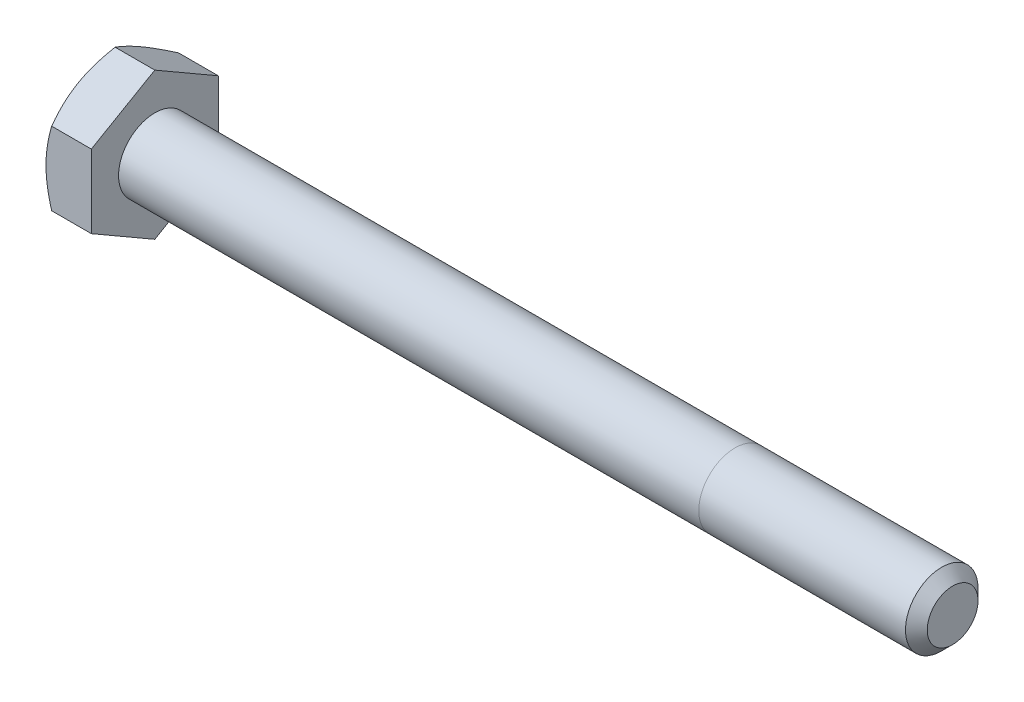
from build123d import *

# Parameters (mm, degrees)
SKETCH5_R           = 3.175
BOSS_EXTRUDE3_DEPTH = 69.85
CHAMFER1_SIZE       = 0.9525
BOSS_EXTRUDE4_DEPTH = 3.96875
SKETCH8_OUTSIDE_W   = 287.44
SKETCH8_OUTSIDE_H   = 289.16
SKETCH8_OUTSIDE_R   = 5.55625
CUT_EXTRUDE3_DEPTH  = 74.81875
CUT_EXTRUDE3_TAPER  = 60
CUT_EXTRUDE4_DEPTH  = 0.254
CIRPATTERN1_COUNT   = 3


with BuildPart() as part:
    # Sketch5 → Boss-Extrude3 (new body)
    with BuildSketch(Plane(origin=(36.909375, 0, 0), x_dir=(0, 0, -1), z_dir=(1, 0, 0))):
        Circle(SKETCH5_R)
    extrude(amount=-BOSS_EXTRUDE3_DEPTH)

    # Chamfer1
    chamfer1_edges = [part.edges().sort_by_distance(p)[0] for p in [
        (36.909375, 0, 3.175),
    ]]
    chamfer(chamfer1_edges, length=CHAMFER1_SIZE)

    # Sketch11 → Revolve1 (revolve)
    with BuildSketch(Plane.XY):
        Polygon((-32.940625, 3.175), (-32.940625, 0), (21.034375, 0), (17.859375, 3.175), align=None)
    revolve(axis=Axis((-32.940625, 0, 0), (1, 0, 0)))

    # Sketch6 → Boss-Extrude4 (add)
    with BuildSketch(Plane.ZY.offset(32.940625)):
        Polygon((5.55625, 3.207902433), (0, 6.415804866), (-5.55625, 3.207902433), (-5.55625, -3.207902433), (0, -6.415804866), (5.55625, -3.207902433), align=None)
    extrude(amount=BOSS_EXTRUDE4_DEPTH)

    # Sketch8 outside → Cut-Extrude3 (cut, through all)
    with BuildSketch(Plane.ZY.offset(36.909375)):
        Rectangle(SKETCH8_OUTSIDE_W, SKETCH8_OUTSIDE_H)
        Circle(SKETCH8_OUTSIDE_R, mode=Mode.SUBTRACT)
    extrude(amount=-CUT_EXTRUDE3_DEPTH, taper=CUT_EXTRUDE3_TAPER, mode=Mode.SUBTRACT)

    # Sketch12 → Cut-Extrude4 (cut)
    with BuildSketch(Plane.ZY.offset(36.909375)):
        with BuildLine():
            Line((0.1666875, 4.2783125), (0.1666875, 2.3891875))
            ThreePointArc((0.1666875, 2.3891875), (0, 2.2225), (-0.1666875, 2.3891875))
            Line((-0.1666875, 2.3891875), (-0.1666875, 4.2783125))
            ThreePointArc((-0.1666875, 4.2783125), (0, 4.445), (0.1666875, 4.2783125))
        make_face()
    cut_extrude4 = extrude(amount=-CUT_EXTRUDE4_DEPTH, mode=Mode.SUBTRACT)

    # CirPattern1: Cut-Extrude4 ×3 about axis
    cirpattern1_axis = Axis((0, 0, 0), (1, 0, 0))
    for i in range(1, CIRPATTERN1_COUNT):
        add(cut_extrude4.rotate(cirpattern1_axis, i * 360 / CIRPATTERN1_COUNT), mode=Mode.SUBTRACT)


solid = part.part
